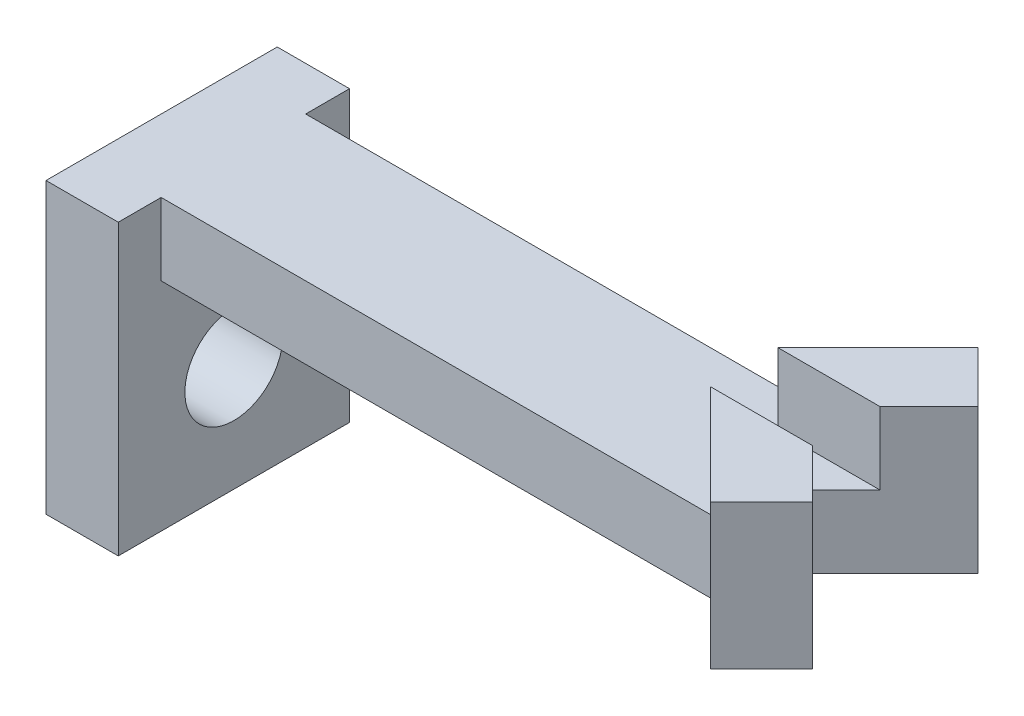
from build123d import *

# Parameters (mm, degrees)
BOSS_EXTRUDE1_DEPTH          = 3.175
BOSS_EXTRUDE2_DEPTH          = 3.175
SKETCH3_W                    = 3.175
SKETCH3_H                    = 10.16
BOSS_EXTRUDE3_DEPTH          = 12.7
F_18_0_1695_DIAMETER_HOLE1_D = 4.3053


with BuildPart() as part:
    # Sketch1 → Boss-Extrude1 (new body)
    with BuildSketch(Plane(origin=(0, 0, 0), x_dir=(1, 0, 0), z_dir=(0, 1, 0))):
        Polygon((20.825839478, -3.654842125), (17.191471303, -0.02047395), (-11.428656758, -0.02047395), (-11.428656758, -3.19547395), (15.876343242, -3.19547395), (18.580775448, -5.899906155), align=None)
    boss_extrude1 = extrude(amount=BOSS_EXTRUDE1_DEPTH)

    # Mirror1: Boss-Extrude1 across plane
    add(boss_extrude1.mirror(Plane(origin=(-11.428656758, 3.175, 0.02047395), x_dir=(1, 0, 0), z_dir=(0, 0, 1))))

    # Sketch2 → Boss-Extrude2 (add)
    with BuildSketch(Plane(origin=(0, 3.175, 0), x_dir=(1, 0, 0), z_dir=(0, 1, 0))):
        Polygon((18.580775448, -5.899906155), (14.18553725, -1.504667957), (18.675665311, -1.504667957), (20.825839478, -3.654842125), align=None)
        Polygon((18.675665311, 1.463720058), (20.825839478, 3.613894225), (18.580775448, 5.858958256), (14.18553725, 1.463720058), align=None)
    extrude(amount=BOSS_EXTRUDE2_DEPTH)

    # Sketch3 → Boss-Extrude3 (add)
    with BuildSketch(Plane(origin=(0, 3.175, 0), x_dir=(1, 0, 0), z_dir=(0, 1, 0))):
        with Locations((-9.841156758, 0)):
            Rectangle(SKETCH3_W, SKETCH3_H)
    extrude(amount=-BOSS_EXTRUDE3_DEPTH)

    # #18 (0.1695) Diameter Hole1 (through all)
    with Locations(Plane(origin=(-8.253656758, 0, 0), x_dir=(0, 0, -1), z_dir=(1, 0, 0))):
        with Locations((0, -4.7625)):
            Hole(F_18_0_1695_DIAMETER_HOLE1_D / 2)


solid = part.part
